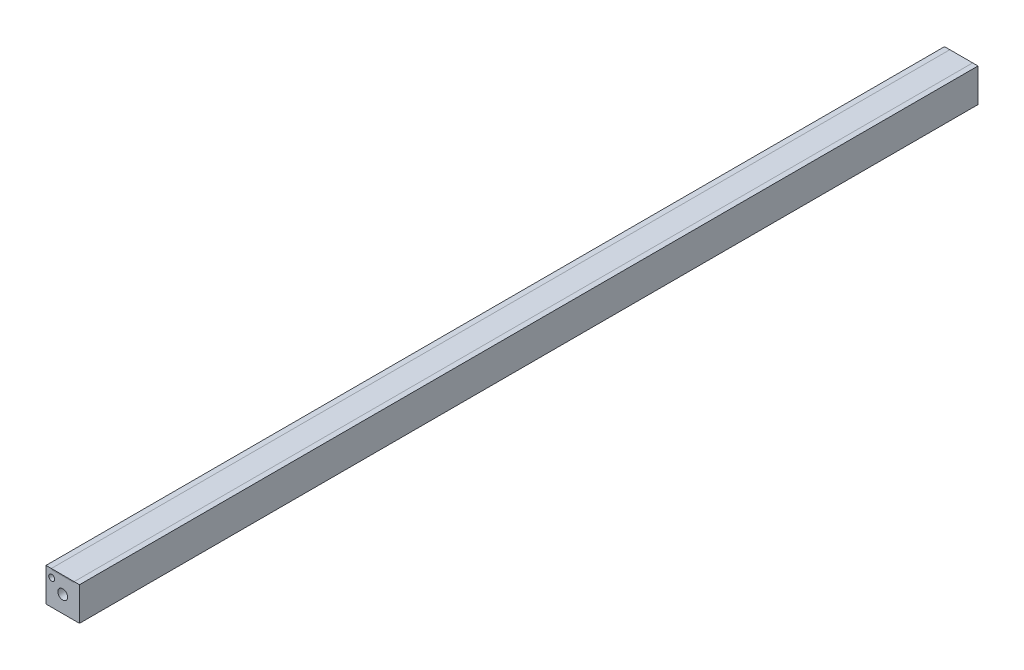
from build123d import *

# Parameters (mm, degrees)
SKETCH1_W           = 18.63
SKETCH1_H           = 18.63
BOSS_EXTRUDE1_DEPTH = 500
SKETCH2_R           = 2.71
CUT_EXTRUDE1_DEPTH  = 24
SKETCH3_R           = 2.71
CUT_EXTRUDE2_DEPTH  = 24
SKETCH4_R           = 1.67
CUT_EXTRUDE3_DEPTH  = 10
SKETCH5_R           = 1.67
CUT_EXTRUDE4_DEPTH  = 10
SKETCH6_W           = 12.7
SKETCH6_H           = 500
CUT_EXTRUDE5_DEPTH  = 0.5
SKETCH7_W           = 12.7
SKETCH7_H           = 500
BOSS_EXTRUDE2_DEPTH = 0.5


with BuildPart() as part:
    # Sketch1 → Boss-Extrude1 (new body)
    with BuildSketch(Plane.XY):
        with Locations((9.315, -9.315)):
            Rectangle(SKETCH1_W, SKETCH1_H)
    extrude(amount=BOSS_EXTRUDE1_DEPTH)

    # Sketch2 → Cut-Extrude1 (cut)
    with BuildSketch(Plane(origin=(0, 0, 0), x_dir=(-1, 0, 0), z_dir=(0, 0, -1))):
        with Locations((-9.315, -9.315)):
            Circle(SKETCH2_R)
    extrude(amount=-CUT_EXTRUDE1_DEPTH, mode=Mode.SUBTRACT)

    # Sketch3 → Cut-Extrude2 (cut)
    with BuildSketch(Plane.XY.offset(500)):
        with Locations((9.315, -9.315)):
            Circle(SKETCH3_R)
    extrude(amount=-CUT_EXTRUDE2_DEPTH, mode=Mode.SUBTRACT)

    # Sketch4 → Cut-Extrude3 (cut)
    with BuildSketch(Plane(origin=(0, 0, 0), x_dir=(-1, 0, 0), z_dir=(0, 0, -1))):
        with Locations((-14.95, -3.73)):
            Circle(SKETCH4_R)
    extrude(amount=-CUT_EXTRUDE3_DEPTH, mode=Mode.SUBTRACT)

    # Sketch5 → Cut-Extrude4 (cut)
    with BuildSketch(Plane.XY.offset(500)):
        with Locations((3.18, -4.345)):
            Circle(SKETCH5_R)
    extrude(amount=-CUT_EXTRUDE4_DEPTH, mode=Mode.SUBTRACT)

    # Sketch6 → Cut-Extrude5 (cut)
    with BuildSketch(Plane(origin=(0, 0, 0), x_dir=(-1, 0, 0), z_dir=(0, 1, 0))):
        with Locations((-9.315, 250)):
            Rectangle(SKETCH6_W, SKETCH6_H)
    extrude(amount=-CUT_EXTRUDE5_DEPTH, mode=Mode.SUBTRACT)


with BuildPart() as body_2:
    # Sketch7 → Boss-Extrude2 (new body)
    with BuildSketch(Plane(origin=(0, 0, 0), x_dir=(-1, 0, 0), z_dir=(0, 1, 0))):
        with Locations((-9.315, 250)):
            Rectangle(SKETCH7_W, SKETCH7_H)
    extrude(amount=-BOSS_EXTRUDE2_DEPTH)


solid = Compound([part.part, body_2.part])
